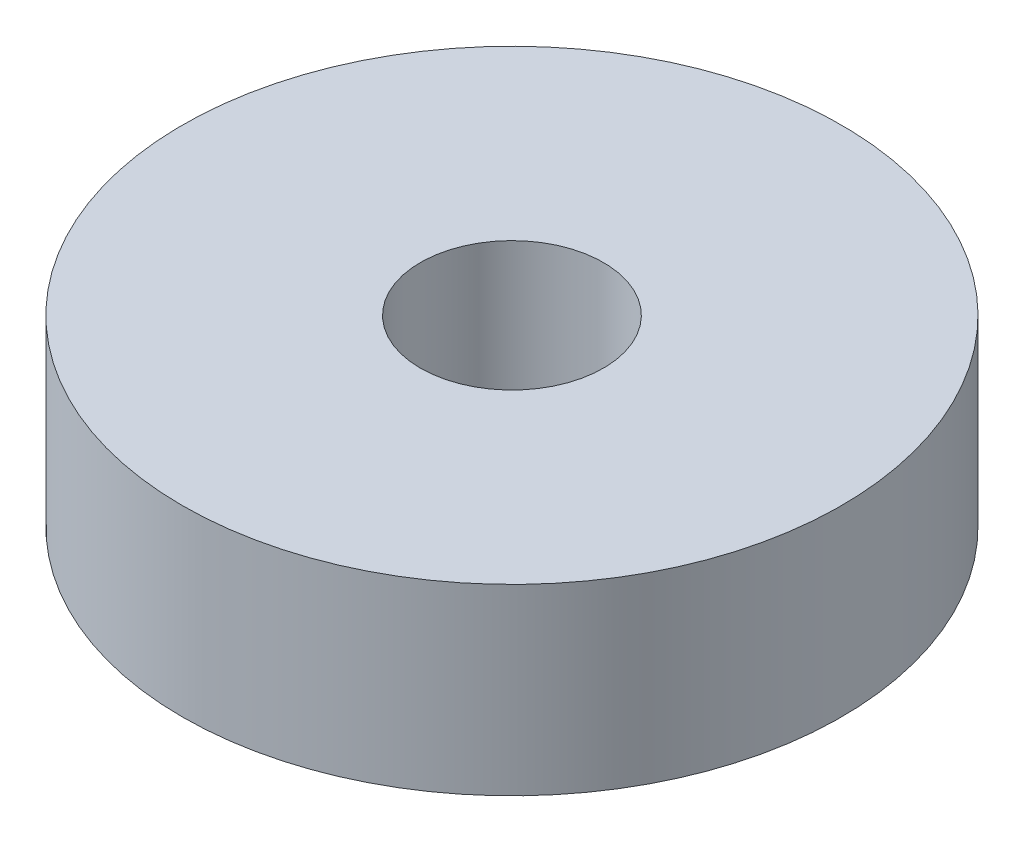
from build123d import *

# Parameters (mm, degrees)
SKETCH1_R           = 9
SKETCH1_R_2         = 2.5
BOSS_EXTRUDE1_DEPTH = 5


with BuildPart() as part:
    # Sketch1 → Boss-Extrude1 (new body)
    with BuildSketch(Plane(origin=(0, 0, 0), x_dir=(1, 0, 0), z_dir=(0, 1, 0))):
        Circle(SKETCH1_R)
        Circle(SKETCH1_R_2, mode=Mode.SUBTRACT)
    extrude(amount=BOSS_EXTRUDE1_DEPTH)


solid = part.part
